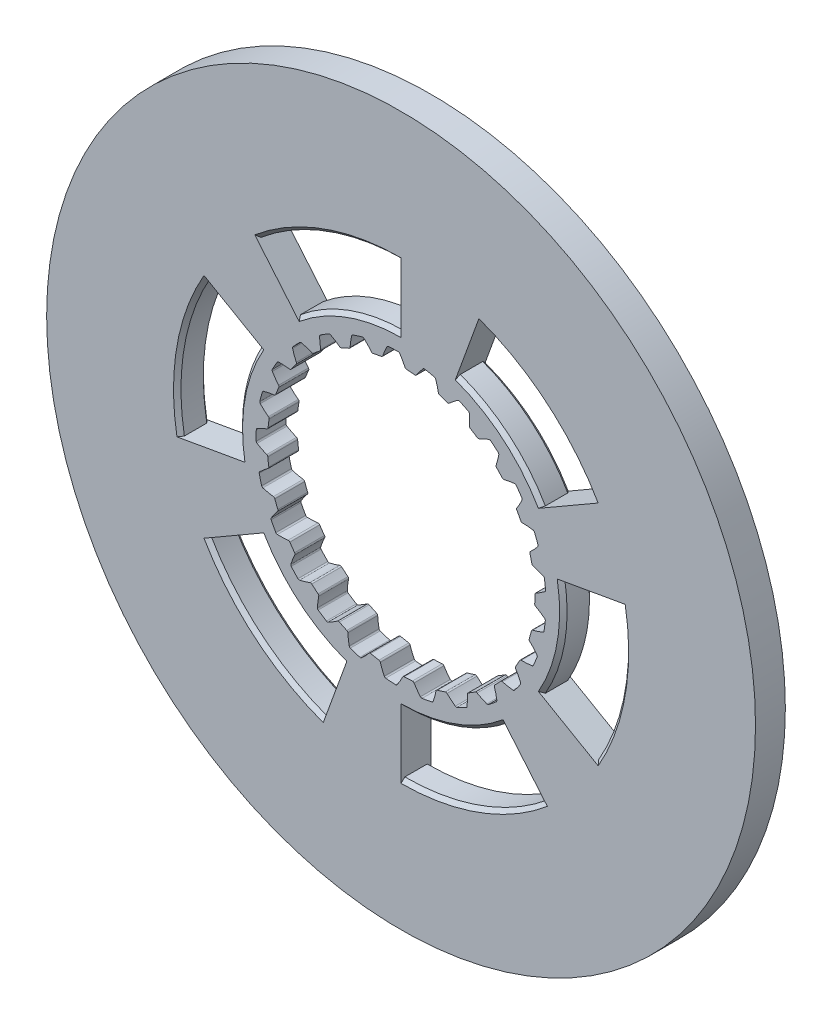
from build123d import *

# Parameters (mm, degrees)
SKETCH1_R                = 95
SKETCH1_R_2              = 35.85
BOSS_EXTRUDE1_DEPTH      = 8
CUT_EXTRUDE1_DEPTH       = 8
FILLET1_R                = 0.48
CIRPATTERN1_COUNT        = 25
FILLET1_OF_CIRPATTERN1_R = 0.48
CUT_EXTRUDE2_DEPTH       = 8
CHAMFER1_SIZE            = 1


with BuildPart() as part:
    # Sketch1 → Boss-Extrude1 (new body)
    with BuildSketch(Plane.XY):
        Circle(SKETCH1_R)
        Circle(SKETCH1_R_2, mode=Mode.SUBTRACT)
    extrude(amount=BOSS_EXTRUDE1_DEPTH)

    # Sketch2 → Cut-Extrude1 (cut)
    with BuildSketch(Plane.XY.offset(8)):
        with BuildLine():
            ThreePointArc((35.833660019, 1.082270585), (35.60665858, 4.169935824), (35.114102213, 7.226501628))
            add(Edge.make_bspline(
                [(35.114102213, 7.226501628), (35.256749104, 7.192417772), (35.550644487, 7.118209111), (35.992167201, 6.995069036), (36.581159742, 6.806547851), (37.167022559, 6.598198987), (37.692835452, 6.389637985), (38.059467989, 6.234671891), (38.285672809, 6.134159981), (38.368646366, 6.09667746)],
                knots=[0.310475903, 0.310475903, 0.310475903, 0.310475903, 0.310475903, 0.361767352, 0.41649966, 0.471231936, 0.525964282, 0.580696615, 0.612361314, 0.612361314, 0.612361314, 0.612361314, 0.612361314], degree=4))
            ThreePointArc((38.368646366, 6.09667746), (38.586295281, 4.518884429), (38.739090073, 2.933496259))
            add(Edge.make_bspline(
                [(35.833660019, 1.082270585), (35.964571851, 1.148391211), (36.233368583, 1.288497378), (36.634492244, 1.510320717), (37.163988833, 1.829829421), (37.685859134, 2.167906157), (38.149255382, 2.492314553), (38.470161804, 2.727799108), (38.667022153, 2.877856656), (38.739090073, 2.933496259)],
                knots=[0.310475903, 0.310475903, 0.310475903, 0.310475903, 0.310475903, 0.361767352, 0.41649966, 0.471231936, 0.525964282, 0.580696615, 0.612361314, 0.612361314, 0.612361314, 0.612361314, 0.612361314], degree=4))
        make_face()
    cut_extrude1 = extrude(amount=-CUT_EXTRUDE1_DEPTH, mode=Mode.SUBTRACT)

    # Fillet1
    fillet1_edges = [part.edges().sort_by_distance(p)[0] for p in [
        (35.833660019, 1.082270585, 4),
        (38.739090073, 2.933496259, 4),
        (35.114102213, 7.226501628, 4),
        (38.368646366, 6.09667746, 4),
    ]]
    fillet(fillet1_edges, radius=FILLET1_R)

    # CirPattern1: Cut-Extrude1 ×25 about axis
    cirpattern1_axis = Axis((0, 0, 8), (0, 0, -1))
    for i in range(1, CIRPATTERN1_COUNT):
        add(cut_extrude1.rotate(cirpattern1_axis, i * 360 / CIRPATTERN1_COUNT), mode=Mode.SUBTRACT)

    # Fillet1 of CirPattern1
    fillet1_of_cirpattern1_edges = [part.edges().sort_by_distance(p)[0] for p in [
        (34.977029446, -7.863199803, 4),
        (38.251561176, -6.79268486, 4),
        (35.808085996, -1.733054327, 4),
        (38.679406815, -3.636755209, 4),
        (31.922663476, -16.314596428, 4),
        (35.360546011, -16.092056607, 4),
        (34.252116043, -10.583716104, 4),
        (36.559797881, -13.141677173, 4),
        (26.862479156, -23.740886958, 4),
        (30.247697693, -24.380305254, 4),
        (30.543959669, -18.769364075, 4),
        (32.143002388, -21.820859229, 4),
        (20.114426478, -29.675450248, 4),
        (23.234275285, -31.136649659, 4),
        (24.916613975, -25.775663871, 4),
        (25.706543842, -29.128956447, 4),
        (12.102510409, -33.745395861, 4),
        (14.760957912, -35.936563853, 4),
        (17.723665789, -31.162383911, 4),
        (17.654848604, -34.606774203, 4),
        (3.3301491, -35.694994144, 4),
        (5.360155266, -38.478451574, 4),
        (9.417074498, -34.591056762, 4),
        (8.493834298, -37.910121062, 4),
        (-5.651457723, -35.401744669, 4),
        (-4.377445649, -38.602596669, 4),
        (0.518773783, -35.846246299, 4),
        (-1.200878854, -38.83143559, 4),
        (-14.277962674, -32.884073377, 4),
        (-13.839995554, -36.301198645, 4),
        (-8.412123397, -34.849084349, 4),
        (-10.820136372, -37.312828208, 4),
        (-22.007330719, -28.300174816, 4),
        (-22.432927639, -31.718862804, 4),
        (-16.814455926, -31.662226263, 4),
        (-19.759524928, -33.449718603, 4),
        (-28.353897238, -21.938072191, 4),
        (-29.616316377, -25.143514159, 4),
        (-24.16027435, -26.485914055, 4),
        (-27.457349862, -27.484840158, 4),
        (-32.918884114, -14.197519807, 4),
        (-34.938803037, -16.988306048, 4),
        (-29.988013882, -19.645394459, 4),
        (-33.429928524, -19.792988125, 4),
        (-35.415456435, -5.564885039, 4),
        (-38.065956205, -7.765660189, 4),
        (-33.931496213, -11.570482478, 4),
        (-37.301981829, -10.857469853, 4),
        (-35.686745379, 3.417411923, 4),
        (-38.801285349, 1.944930659, 4),
        (-35.742937845, -2.76855453, 4),
        (-38.830214429, -1.23973682, 4),
        (-33.715704864, 12.184980324, 4),
        (-37.098587033, 11.533314362, 4),
        (-35.30851924, 6.207331881, 4),
        (-37.918601849, 8.455893437, 4),
        (-29.626182615, 20.186921599, 4),
        (-33.064848054, 20.397017506, 4),
        (-32.655536515, 14.793188802, 4),
        (-34.62442406, 17.62020881, 4),
        (-23.675138355, 26.920444348, 4),
        (-26.953523069, 27.979101025, 4),
        (-27.950686332, 22.449535264, 4),
        (-29.154666367, 25.677381662, 4),
        (-16.23649808, 31.962456571, 4),
        (-19.148609101, 33.803154727, 4),
        (-21.489591732, 28.695294862, 4),
        (-21.853013764, 32.121150189, 4),
        (-7.777658918, 34.996150099, 4),
        (-10.140517599, 37.503231898, 4),
        (-13.67822705, 33.13802355, 4),
        (-13.178255935, 36.546628716, 4),
        (1.169879158, 35.830906809, 4),
        (-0.495260082, 38.846843082, 4),
        (-5.007409057, 35.498568345, 4),
        (-3.67545982, 38.675748152, 4),
        (10.043909424, 34.414275867, 4),
        (9.181116447, 37.749564246, 4),
        (3.978042863, 35.628607536, 4),
        (6.058278952, 38.374728092, 4),
        (18.286843923, 30.835269406, 4),
        (18.280609664, 34.280341456, 4),
        (12.713539719, 33.519970283, 4),
        (15.411353778, 35.662482734, 4),
        (25.380748763, 25.318769564, 4),
        (26.231464944, 28.657158737, 4),
        (20.650198118, 29.30515002, 4),
        (23.796076567, 30.709432428, 4),
        (30.879887815, 18.211398314, 4),
        (32.534100809, 21.233341342, 4),
        (27.289328623, 23.248979404, 4),
        (30.685604349, 23.826795541, 4),
        (34.438729947, 9.959737931, 4),
        (36.792499469, 12.475355019, 4),
        (32.213770247, 15.731989908, 4),
        (35.647042756, 15.447033462, 4),
    ]]
    fillet(fillet1_of_cirpattern1_edges, radius=FILLET1_OF_CIRPATTERN1_R)

    # Sketch3 → Cut-Extrude2 (cut)
    with BuildSketch(Plane.XY.offset(8)):
        with BuildLine():
            ThreePointArc((-27.961261021, 33.322933276), (-14.877876235, 40.876629004), (0, 43.5))
            Line((0, 43.5), (0, 60))
            ThreePointArc((0, 60), (-20.5212086, 56.381557247), (-38.567256581, 45.962666587))
            Line((-38.567256581, 45.962666587), (-27.961261021, 33.322933276))
        make_face()
        with BuildLine():
            Line((-59.088465181, -10.41889066), (-42.839137256, -7.553695729))
            ThreePointArc((-42.839137256, -7.553695729), (-42.839137256, 7.553695729), (-37.672105065, 21.75))
            Line((-37.672105065, 21.75), (-51.961524227, 30))
            ThreePointArc((-51.961524227, 30), (-59.088465181, 10.41889066), (-59.088465181, -10.41889066))
        make_face()
        with BuildLine():
            Line((-20.5212086, -56.381557247), (-14.877876235, -40.876629004))
            ThreePointArc((-14.877876235, -40.876629004), (-27.961261021, -33.322933276), (-37.672105065, -21.75))
            Line((-37.672105065, -21.75), (-51.961524227, -30))
            ThreePointArc((-51.961524227, -30), (-38.567256581, -45.962666587), (-20.5212086, -56.381557247))
        make_face()
        with BuildLine():
            Line((20.5212086, 56.381557247), (14.877876235, 40.876629004))
            ThreePointArc((14.877876235, 40.876629004), (27.961261021, 33.322933276), (37.672105065, 21.75))
            Line((37.672105065, 21.75), (51.961524227, 30))
            ThreePointArc((51.961524227, 30), (38.567256581, 45.962666587), (20.5212086, 56.381557247))
        make_face()
        with BuildLine():
            Line((59.088465181, 10.41889066), (42.839137256, 7.553695729))
            ThreePointArc((42.839137256, 7.553695729), (43.334469367, 3.79127481), (43.5, 0))
            ThreePointArc((43.5, 0), (42.017773444, -11.258628462), (37.672105065, -21.75))
            Line((37.672105065, -21.75), (51.961524227, -30))
            ThreePointArc((51.961524227, -30), (57.955549577, -15.529142706), (60, 0))
            ThreePointArc((60, 0), (59.771681886, 5.229344565), (59.088465181, 10.41889066))
        make_face()
        with BuildLine():
            Line((38.567256581, -45.962666587), (27.961261021, -33.322933276))
            ThreePointArc((27.961261021, -33.322933276), (14.877876235, -40.876629004), (0, -43.5))
            Line((0, -43.5), (0, -60))
            ThreePointArc((0, -60), (20.5212086, -56.381557247), (38.567256581, -45.962666587))
        make_face()
    extrude(amount=-CUT_EXTRUDE2_DEPTH, mode=Mode.SUBTRACT)

    # Chamfer1
    chamfer1_edges = [part.edges().sort_by_distance(p)[0] for p in [
        (-42.839137256, 7.553695729, 8),
        (-59.088465181, 10.41889066, 0),
        (-42.839137256, 7.553695729, 0),
        (-59.088465181, 10.41889066, 8),
        (-27.961261021, -33.322933276, 8),
        (-38.567256581, -45.962666587, 0),
        (-27.961261021, -33.322933276, 0),
        (-38.567256581, -45.962666587, 8),
        (27.961261021, 33.322933276, 8),
        (38.567256581, 45.962666587, 0),
        (27.961261021, 33.322933276, 0),
        (38.567256581, 45.962666587, 8),
        (42.839137256, -7.553695729, 8),
        (59.088465181, -10.41889066, 0),
        (42.839137256, -7.553695729, 0),
        (59.088465181, -10.41889066, 8),
        (14.877876235, -40.876629004, 8),
        (20.5212086, -56.381557247, 0),
        (14.877876235, -40.876629004, 0),
        (20.5212086, -56.381557247, 8),
        (-14.877876235, 40.876629004, 8),
        (-20.5212086, 56.381557247, 0),
        (-14.877876235, 40.876629004, 0),
        (-20.5212086, 56.381557247, 8),
    ]]
    chamfer(chamfer1_edges, length=CHAMFER1_SIZE)


solid = part.part
